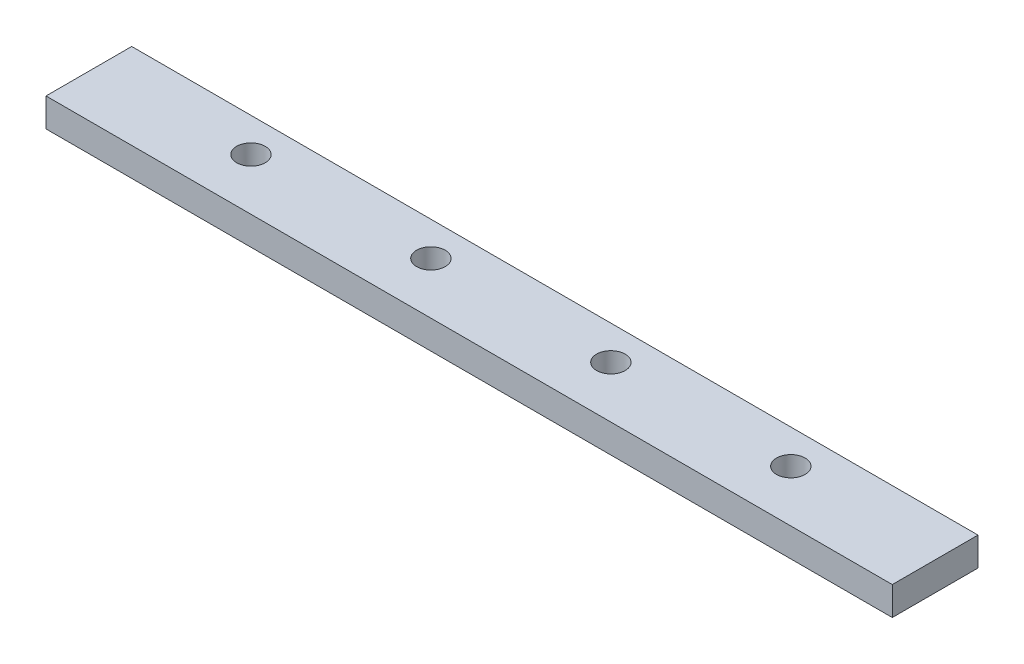
from build123d import *

# Parameters (mm, degrees)
SKETCH1_W               = 38.1
SKETCH1_H               = 12.7
BOSS_EXTRUDE1_DEPTH     = 376.2
SKETCH2_R               = 6.35
CUT_EXTRUDE1_DEPTH      = 1
CUT_EXTRUDE1_DEPTH_BACK = 13.7


with BuildPart() as part:
    # Sketch1 → Boss-Extrude1 (new body)
    with BuildSketch(Plane(origin=(0, 0, 0), x_dir=(0, 0, -1), z_dir=(1, 0, 0))):
        with Locations((19.05, 6.35)):
            Rectangle(SKETCH1_W, SKETCH1_H)
    extrude(amount=BOSS_EXTRUDE1_DEPTH)

    # Sketch2 → Cut-Extrude1 (cut, two sides)
    with BuildSketch(Plane(origin=(0, 12.7, 0), x_dir=(1, 0, 0), z_dir=(0, 1, 0))) as cut_extrude1_sk:
        with Locations((308.1, 23)):
            Circle(SKETCH2_R)
        with Locations((228.1, 23)):
            Circle(SKETCH2_R)
        with Locations((148.1, 23)):
            Circle(SKETCH2_R)
        with Locations((68.1, 23)):
            Circle(SKETCH2_R)
    extrude(amount=CUT_EXTRUDE1_DEPTH, mode=Mode.SUBTRACT)
    extrude(cut_extrude1_sk.sketch, amount=-CUT_EXTRUDE1_DEPTH_BACK, mode=Mode.SUBTRACT)


solid = part.part
